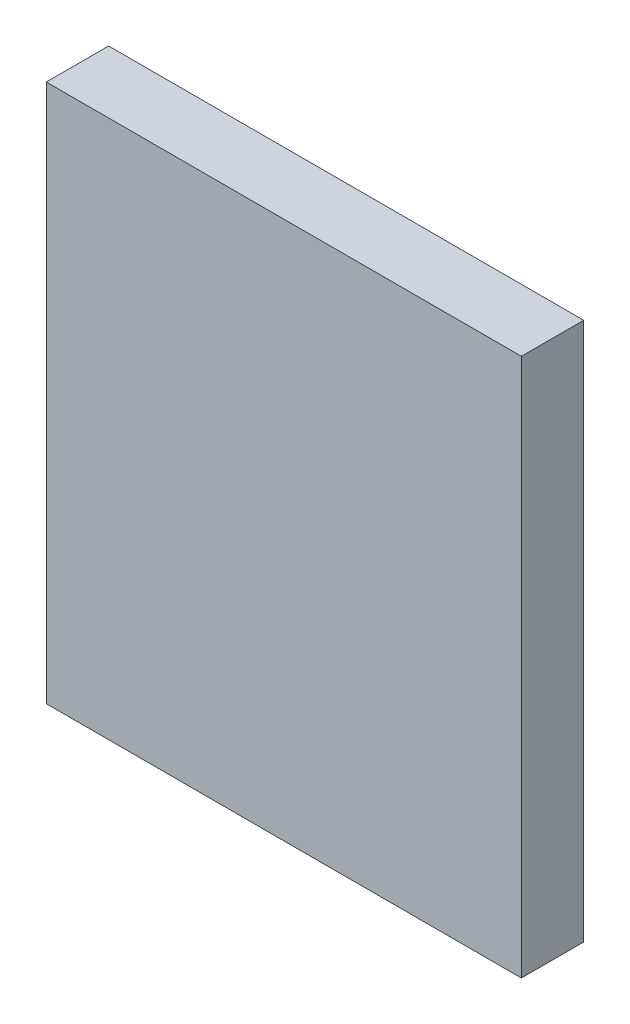
from build123d import *

# Parameters (mm, degrees)
SKETCH1_W               = 7.62
SKETCH1_H               = 8.636
COMPONENT_OUTLINE_DEPTH = 1


with BuildPart() as part:
    # Sketch1 → Component_Outline (new body)
    with BuildSketch(Plane.XY):
        Rectangle(SKETCH1_W, SKETCH1_H)
    extrude(amount=COMPONENT_OUTLINE_DEPTH)


solid = part.part
